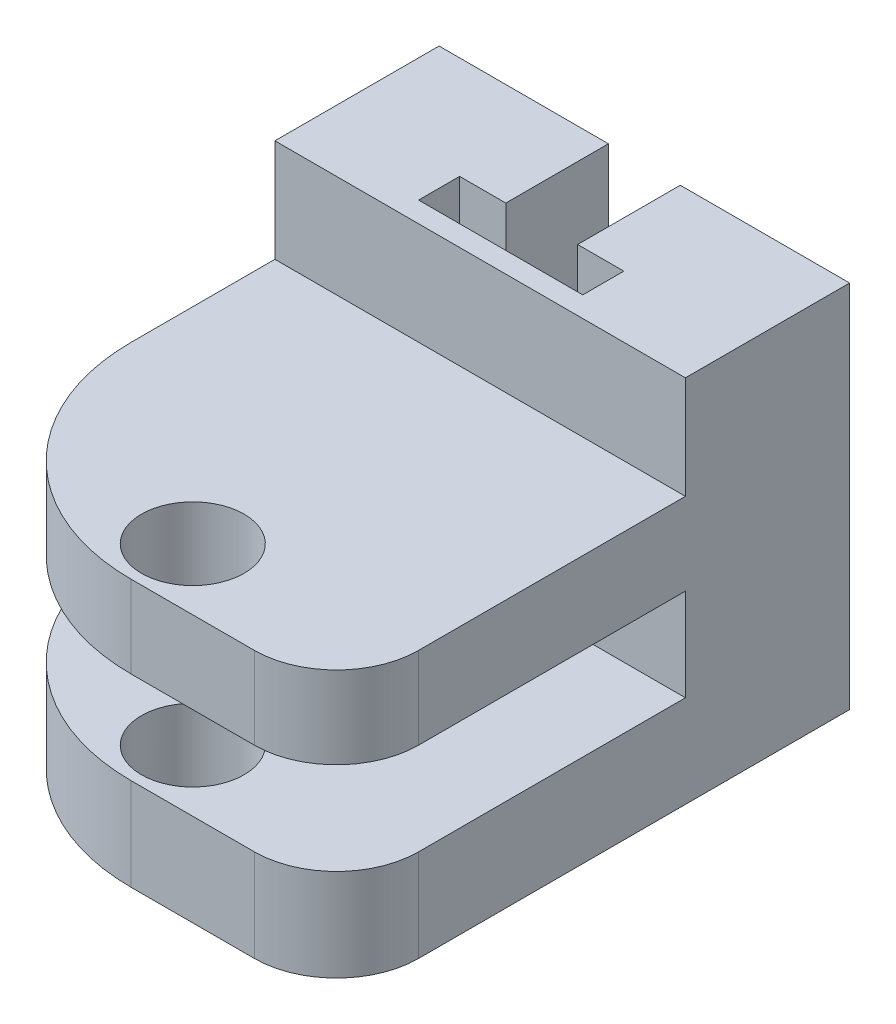
from build123d import *

# Parameters (mm, degrees)
CROQUIS1_R              = 2.5
SALIENTE_EXTRUIR1_DEPTH = 3
REDONDEO1_R             = 4
SALIENTE_EXTRUIR2_DEPTH = 15
CROQUIS3_W              = 9.109730849
CROQUIS3_H              = 7.453923598
SALIENTE_EXTRUIR3_DEPTH = 4
CROQUIS4_R              = 2.5
SALIENTE_EXTRUIR4_DEPTH = 13
CROQUIS5_W              = 20
CROQUIS5_H              = 4.5
CORTAR_EXTRUIR1_DEPTH   = 17
CORTAR_EXTRUIR2_DEPTH   = 6.5


with BuildPart() as part:
    # Croquis1 → Saliente-Extruir1 (new body)
    with BuildSketch(Plane(origin=(0, 0, 0), x_dir=(1, 0, 0), z_dir=(0, 1, 0))):
        with BuildLine():
            Line((-1.502919204, 4.425183821), (-1.502919204, -0.574816179))
            Line((-1.502919204, -0.574816179), (-3.752919204, -0.574816179))
            Line((-3.752919204, -0.574816179), (-3.752919204, -2.574816179))
            Line((-3.752919204, -2.574816179), (4.247080796, -2.574816179))
            Line((4.247080796, -2.574816179), (4.247080796, -0.574816179))
            Line((4.247080796, -0.574816179), (1.997080796, -0.574816179))
            Line((1.997080796, -0.574816179), (1.997080796, 4.425183821))
            Line((1.997080796, 4.425183821), (10.247080796, 4.425183821))
            Line((10.247080796, 4.425183821), (10.247080796, -9.382782341))
            Line((10.247080796, -9.382782341), (10.247080796, -20.574816179))
            Line((10.247080796, -20.574816179), (0.247080796, -20.574816179))
            ThreePointArc((0.247080796, -20.574816179), (-6.823987016, -17.645883991), (-9.752919204, -10.574816179))
            Line((-9.752919204, -10.574816179), (-9.752919204, 4.425183821))
            Line((-9.752919204, 4.425183821), (-1.502919204, 4.425183821))
        make_face()
        with Locations((0.247080796, -17.574816179)):
            Circle(CROQUIS1_R, mode=Mode.SUBTRACT)
    extrude(amount=SALIENTE_EXTRUIR1_DEPTH)

    # Redondeo1
    redondeo1_edges = [part.edges().sort_by_distance(p)[0] for p in [
        (10.247080796, 1.5, 20.574816179),
    ]]
    fillet(redondeo1_edges, radius=REDONDEO1_R)

    # Croquis2 → Saliente-Extruir2 (add)
    with BuildSketch(Plane(origin=(0, 3, 0), x_dir=(1, 0, 0), z_dir=(0, 1, 0))):
        Polygon((-9.752919204, -3.574816179), (10.247080796, -3.574816179), (10.247080796, 4.425183821), (1.997080796, 4.425183821), (1.997080796, -0.574816179), (4.247080796, -0.574816179), (4.247080796, -2.574816179), (-3.752919204, -2.574816179), (-3.752919204, -0.574816179), (-1.502919204, -0.574816179), (-1.502919204, 4.425183821), (-9.752919204, 4.425183821), align=None)
    extrude(amount=SALIENTE_EXTRUIR2_DEPTH)

    # Croquis3 → Saliente-Extruir3 (add)
    with BuildSketch(Plane.XZ):
        with Locations((0.202425252, -0.698222022)):
            Rectangle(CROQUIS3_W, CROQUIS3_H)
    extrude(amount=-SALIENTE_EXTRUIR3_DEPTH)

    # Croquis4 → Saliente-Extruir4 (add)
    with BuildSketch(Plane.XZ):
        with BuildLine():
            Line((-9.752919204, -4.425183821), (10.247080796, -4.425183821))
            Line((10.247080796, -4.425183821), (10.247080796, 16.574816179))
            ThreePointArc((10.247080796, 16.574816179), (9.075507921, 19.403243304), (6.247080796, 20.574816179))
            Line((6.247080796, 20.574816179), (0.247080796, 20.574816179))
            ThreePointArc((0.247080796, 20.574816179), (-6.823987016, 17.645883991), (-9.752919204, 10.574816179))
            Line((-9.752919204, 10.574816179), (-9.752919204, -4.425183821))
        make_face()
        with Locations((0.247080796, 17.574816179)):
            Circle(CROQUIS4_R, mode=Mode.SUBTRACT)
    extrude(amount=-SALIENTE_EXTRUIR4_DEPTH)

    # Croquis5 → Cortar-Extruir1 (cut)
    with BuildSketch(Plane.XY.offset(20.574816179)):
        with Locations((0.247080796, 6.75)):
            Rectangle(CROQUIS5_W, CROQUIS5_H)
    extrude(amount=-CORTAR_EXTRUIR1_DEPTH, mode=Mode.SUBTRACT)

    # Croquis6 → Cortar-Extruir2 (cut)
    with BuildSketch(Plane(origin=(0, 13, 0), x_dir=(1, 0, 0), z_dir=(0, 1, 0))):
        Polygon((-1.502919204, 4.425183821), (-1.502919204, -0.574816179), (-3.752919204, -0.574816179), (-3.752919204, -2.574816179), (4.247080796, -2.574816179), (4.247080796, -0.574816179), (1.997080796, -0.574816179), (1.997080796, 4.425183821), align=None)
    extrude(amount=-CORTAR_EXTRUIR2_DEPTH, mode=Mode.SUBTRACT)


solid = part.part
